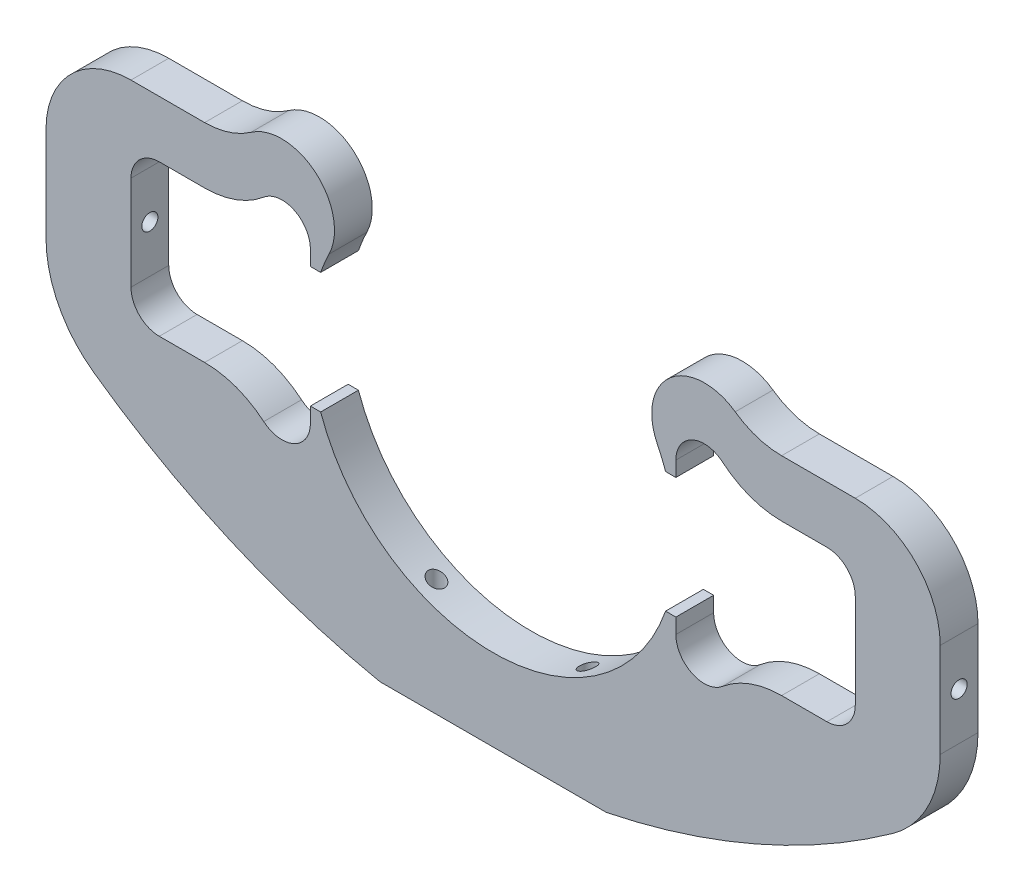
from build123d import *

# Parameters (mm, degrees)
BOSS_EXTRUDE1_DEPTH   = 6.35
F_6_32_TAPPED_HOLE2_D = 2.7051
F_6_32_TAPPED_HOLE1_D = 2.7051


with BuildPart() as part:
    # Sketch1 → Boss-Extrude1 (new body)
    with BuildSketch(Plane.XY):
        with BuildLine():
            Line((-30.725, 12.7), (-30.725, 10.16))
            Line((-30.725, 10.16), (-28.99655195, 10.16))
            ThreePointArc((-28.99655195, 10.16), (-28.338337344, 11.872837132), (-27.579048351, 13.5433274))
            ThreePointArc((-27.579048351, 13.5433274), (-29.797475058, 24.232437752), (-40.703834208, 24.711840767))
            ThreePointArc((-40.703834208, 24.711840767), (-44.411023794, 22.861749744), (-48.505, 22.225))
            Line((-48.505, 22.225), (-60.8875, 22.225))
            ThreePointArc((-60.8875, 22.225), (-70.990288136, 18.040288136), (-75.175, 7.9375))
            Line((-75.175, 7.9375), (-75.175, -7.9375))
            ThreePointArc((-75.175, -7.9375), (-73.061327111, -16.658929011), (-67.189349187, -23.445003896))
            ThreePointArc((-67.189349187, -23.445003896), (-44.21739693, -36.463267178), (-19.05, -44.45))
            Line((-19.05, -44.45), (0, -44.45))
            Line((0, -44.45), (0, -30.725))
            ThreePointArc((0, -30.725), (-17.774414547, -25.061839767), (-28.99655195, -10.16))
            Line((-28.99655195, -10.16), (-30.725, -10.16))
            Line((-30.725, -10.16), (-30.725, -12.7))
            ThreePointArc((-30.725, -12.7), (-33.481957403, -17.019630209), (-38.560886674, -16.338090241))
            ThreePointArc((-38.560886674, -16.338090241), (-43.210637658, -13.638076264), (-48.505, -12.7))
            Line((-48.505, -12.7), (-56.125, -12.7))
            ThreePointArc((-56.125, -12.7), (-59.492596045, -11.305096045), (-60.8875, -7.9375))
            Line((-60.8875, -7.9375), (-60.8875, 7.9375))
            ThreePointArc((-60.8875, 7.9375), (-59.492596045, 11.305096045), (-56.125, 12.7))
            Line((-56.125, 12.7), (-48.505, 12.7))
            ThreePointArc((-48.505, 12.7), (-43.210637658, 13.638076264), (-38.560886674, 16.338090241))
            ThreePointArc((-38.560886674, 16.338090241), (-33.481957403, 17.019630209), (-30.725, 12.7))
        make_face()
    boss_extrude1 = extrude(amount=BOSS_EXTRUDE1_DEPTH)

    # Mirror1: Boss-Extrude1 across plane
    add(boss_extrude1.mirror(Plane(origin=(0, -30.725, 6.35), x_dir=(0, 0, 1), z_dir=(-1, 0, 0))))

    # #6-32 Tapped Hole2 (through all)
    with Locations(Plane(origin=(0, -44.45, 0), x_dir=(-1, 0, 0), z_dir=(0, -1, 0))):
        with Locations((-12.7, -3.175), (12.7, -3.175)):
            Hole(F_6_32_TAPPED_HOLE2_D / 2)

    # #6-32 Tapped Hole1 (through all)
    with Locations(Plane.ZY.offset(75.175)):
        with Locations((3.175, 0)):
            Hole(F_6_32_TAPPED_HOLE1_D / 2)


solid = part.part
